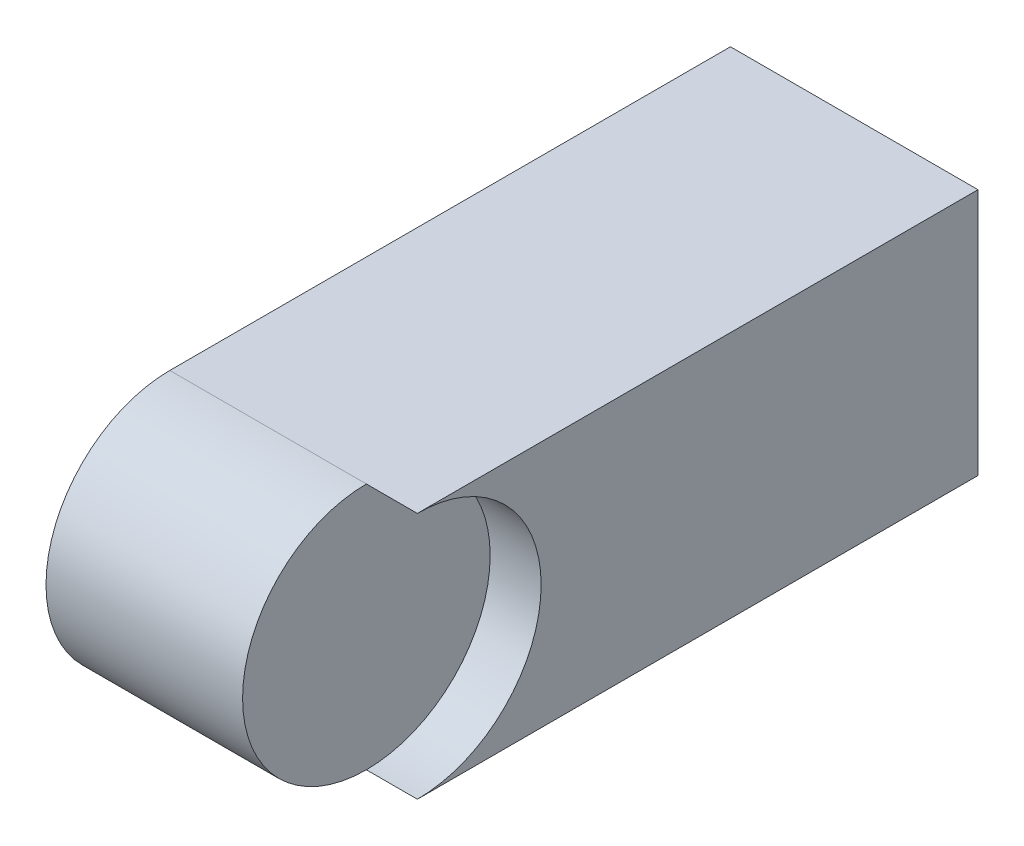
from build123d import *

# Parameters (mm, degrees)
SKETCH2_W           = 17
SKETCH2_H           = 17
BOSS_EXTRUDE1_DEPTH = 47
CUT_EXTRUDE1_DEPTH  = 47
SKETCH6_R           = 8.5
CUT_EXTRUDE3_DEPTH  = 3.5


with BuildPart() as part:
    # Sketch2 → Boss-Extrude1 (new body)
    with BuildSketch(Plane.XY):
        Rectangle(SKETCH2_W, SKETCH2_H)
    extrude(amount=BOSS_EXTRUDE1_DEPTH)

    # Sketch3 → Cut-Extrude1 (cut)
    with BuildSketch(Plane(origin=(8.5, 0, 0), x_dir=(0, 0, -1), z_dir=(1, 0, 0))):
        with BuildLine():
            Line((-38.5, 8.5), (-47, 8.5))
            Line((-47, 8.5), (-47, 0))
            ThreePointArc((-47, 0), (-44.51040764, 6.01040764), (-38.5, 8.5))
        make_face()
        with BuildLine():
            ThreePointArc((-38.5, -8.5), (-44.51040764, -6.01040764), (-47, 0))
            Line((-47, 0), (-47, -8.5))
            Line((-47, -8.5), (-38.5, -8.5))
        make_face()
    extrude(amount=-CUT_EXTRUDE1_DEPTH, mode=Mode.SUBTRACT)

    # Sketch6 → Cut-Extrude3 (cut)
    with BuildSketch(Plane(origin=(8.5, 0, 0), x_dir=(0, 0, -1), z_dir=(1, 0, 0))):
        with Locations((-38.5, 0)):
            Circle(SKETCH6_R)
    extrude(amount=-CUT_EXTRUDE3_DEPTH, mode=Mode.SUBTRACT)


solid = part.part
